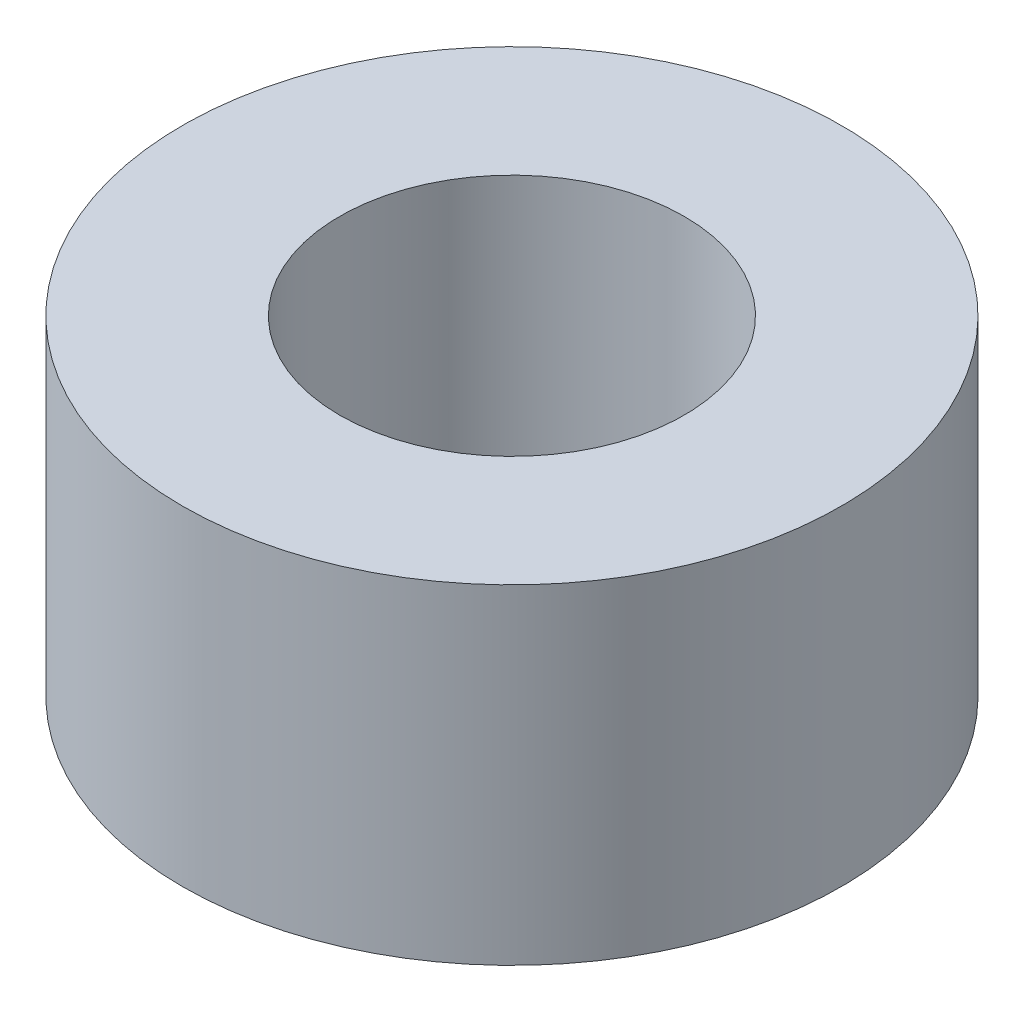
from build123d import *

# Parameters (mm, degrees)
SKETCH1_R           = 4.7625
SKETCH1_R_2         = 2.4892
BOSS_EXTRUDE1_DEPTH = 4.7625


with BuildPart() as part:
    # Sketch1 → Boss-Extrude1 (new body)
    with BuildSketch(Plane(origin=(0, 0, 0), x_dir=(1, 0, 0), z_dir=(0, 1, 0))):
        Circle(SKETCH1_R)
        Circle(SKETCH1_R_2, mode=Mode.SUBTRACT)
    extrude(amount=BOSS_EXTRUDE1_DEPTH)


solid = part.part
